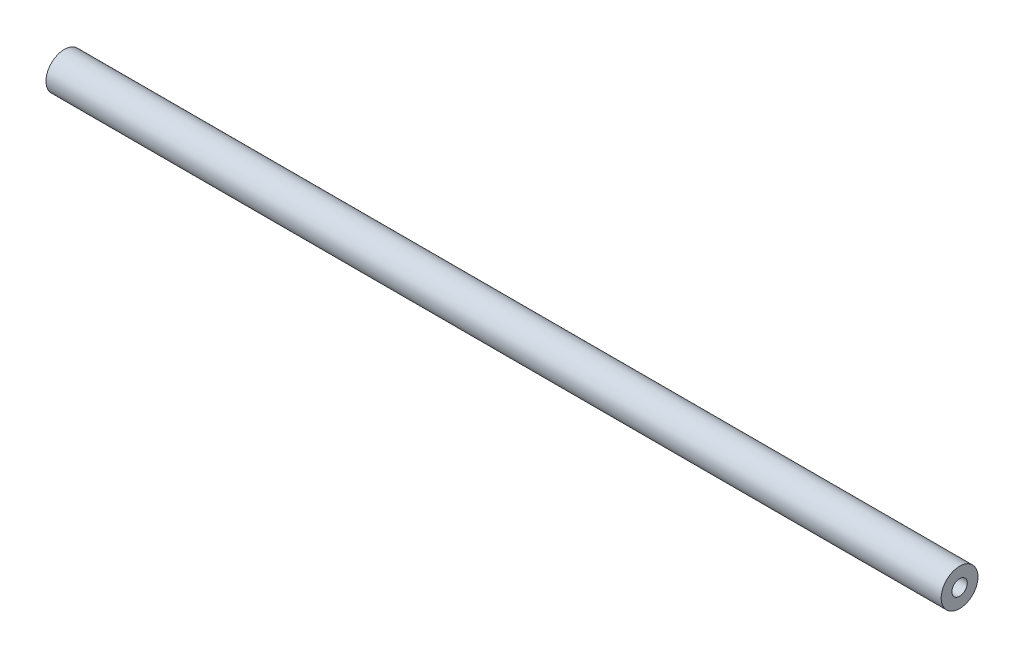
from build123d import *

# Parameters (mm, degrees)
SKETCH1_R           = 9.525
SKETCH1_R_2         = 3.96875
BOSS_EXTRUDE1_DEPTH = 231.7115


with BuildPart() as part:
    # Sketch1 → Boss-Extrude1 (new body, symmetric)
    with BuildSketch(Plane(origin=(0, 0, 0), x_dir=(0, 0, -1), z_dir=(1, 0, 0))):
        Circle(SKETCH1_R)
        Circle(SKETCH1_R_2, mode=Mode.SUBTRACT)
    extrude(amount=BOSS_EXTRUDE1_DEPTH, both=True)


solid = part.part
